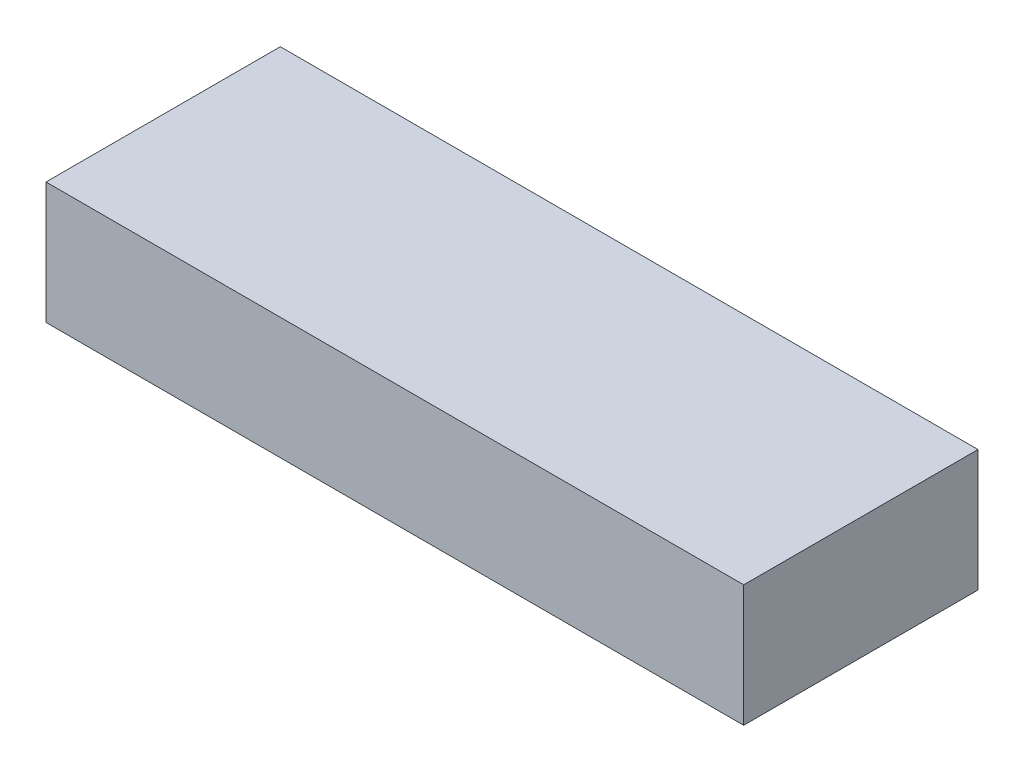
from build123d import *

# Parameters (mm, degrees)
SKETCH2_W           = 136.906
SKETCH2_H           = 45.974
BOSS_EXTRUDE1_DEPTH = 23.876


with BuildPart() as part:
    # Sketch2 → Boss-Extrude1 (new body)
    with BuildSketch(Plane(origin=(0, 0, 0), x_dir=(1, 0, 0), z_dir=(0, 1, 0))):
        Rectangle(SKETCH2_W, SKETCH2_H)
    extrude(amount=BOSS_EXTRUDE1_DEPTH)


solid = part.part
